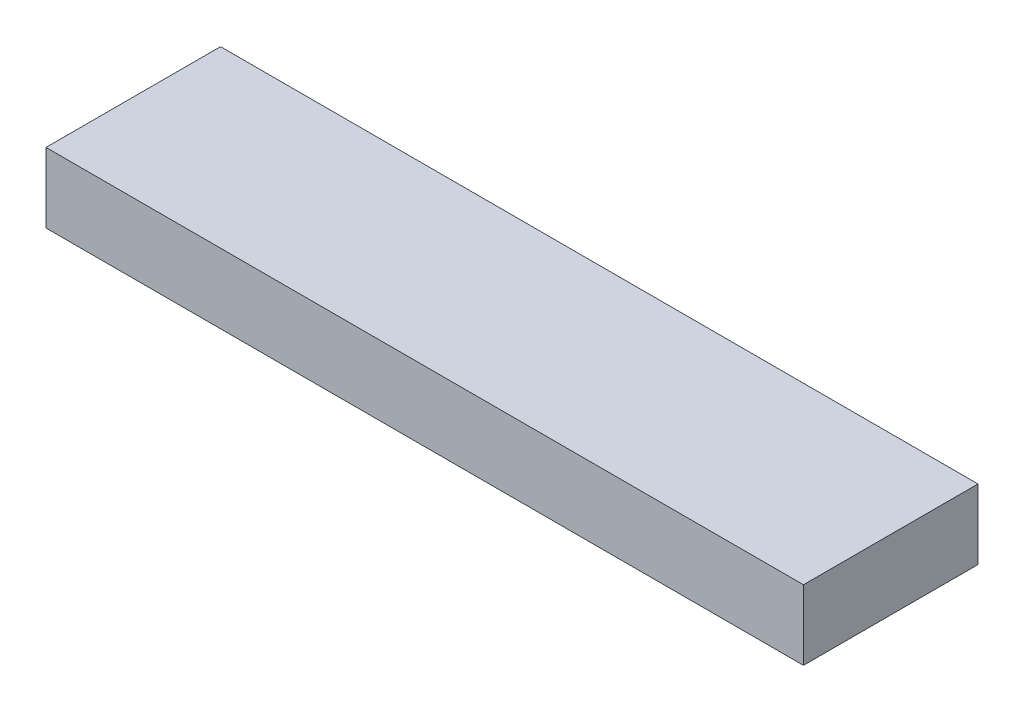
from build123d import *

# Parameters (mm, degrees)
SKETCH1_W           = 2.17
SKETCH1_H           = 0.5
BOSS_EXTRUDE1_DEPTH = 0.2


with BuildPart() as part:
    # Sketch1 → Boss-Extrude1 (new body)
    with BuildSketch(Plane(origin=(0, 0, 0), x_dir=(1, 0, 0), z_dir=(0, 1, 0))):
        with Locations((1.085, 0.25)):
            Rectangle(SKETCH1_W, SKETCH1_H)
    extrude(amount=BOSS_EXTRUDE1_DEPTH)


solid = part.part
